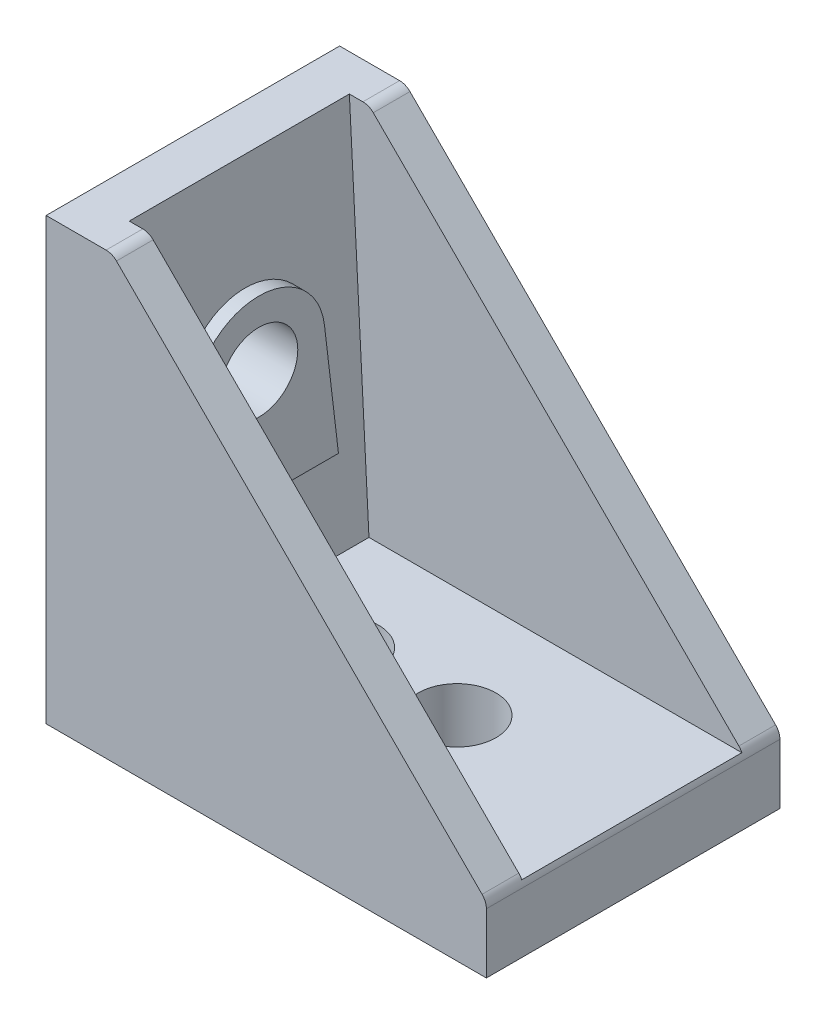
from build123d import *

# Parameters (mm, degrees)
BOSS_EXTRUDE1_DEPTH = 10
CUT_EXTRUDE1_DEPTH  = 7.5
BOSS_EXTRUDE2_DEPTH = 4.5
DIAMETER_HOLE1_D    = 5.3
BOSS_EXTRUDE3_START = 1
BOSS_EXTRUDE3_DEPTH = 1
DIAMETER_HOLE2_D    = 5.3
BOSS_EXTRUDE4_DEPTH = 1


with BuildPart() as part:
    # Sketch1 → Boss-Extrude1 (new, symmetric)
    with BuildSketch(Plane.XY):
        with BuildLine():
            Line((0, 0), (0, 30))
            Line((0, 30), (4.085786438, 30))
            ThreePointArc((4.085786438, 30), (4.46846987, 29.923879533), (4.792893219, 29.707106781))
            Line((4.792893219, 29.707106781), (29.707106781, 4.792893219))
            ThreePointArc((29.707106781, 4.792893219), (29.923879533, 4.46846987), (30, 4.085786438))
            Line((30, 4.085786438), (30, 0))
            Line((30, 0), (0, 0))
        make_face()
    extrude(amount=BOSS_EXTRUDE1_DEPTH, both=True)

    # Sketch2 → Cut-Extrude1 (cut, symmetric)
    with BuildSketch(Plane.XY):
        with BuildLine():
            Line((3.163601628, 30), (4.5, 4.5))
            Line((4.5, 4.5), (29.910179721, 4.5))
            ThreePointArc((29.910179721, 4.5), (29.821797126, 4.655566643), (29.707106781, 4.792893219))
            Line((29.707106781, 4.792893219), (4.792893219, 29.707106781))
            ThreePointArc((4.792893219, 29.707106781), (4.46846987, 29.923879533), (4.085786438, 30))
            Line((4.085786438, 30), (3.163601628, 30))
        make_face()
    extrude(amount=CUT_EXTRUDE1_DEPTH, both=True, mode=Mode.SUBTRACT)

    # Sketch3 → Boss-Extrude2 (add)
    with BuildSketch(Plane.ZY):
        with BuildLine():
            Line((-5.420869488, 10.5), (5.420869488, 10.5))
            Line((5.420869488, 10.5), (4.468692558, 18.529893219))
            ThreePointArc((4.468692558, 18.529893219), (0, 22.5), (-4.468692558, 18.529893219))
            Line((-4.468692558, 18.529893219), (-5.420869488, 10.5))
        make_face()
    extrude(amount=-BOSS_EXTRUDE2_DEPTH)

    # Diameter Hole1 (through all)
    with Locations(Plane(origin=(0, 4.5, 0), x_dir=(1, 0, 0), z_dir=(0, 1, 0))):
        with Locations((10, 0), (18, 0)):
            Hole(DIAMETER_HOLE1_D / 2)

    # Sketch6 → Boss-Extrude3 (add)
    with BuildSketch(Plane.XZ.offset(BOSS_EXTRUDE3_START)):
        with BuildLine():
            Line((13, -0.5), (12.602402736, -0.5))
            ThreePointArc((12.602402736, -0.5), (11.87383297, -1.87383297), (10.5, -2.602402736))
            Line((10.5, -2.602402736), (10.5, -3))
            Line((10.5, -3), (12, -3))
            ThreePointArc((12, -3), (12.707106781, -2.707106781), (13, -2))
            Line((13, -2), (13, -0.5))
        make_face()
        with BuildLine():
            Line((9.5, -3), (9.5, -2.602402736))
            ThreePointArc((9.5, -2.602402736), (8.12616703, -1.87383297), (7.397597264, -0.5))
            Line((7.397597264, -0.5), (7, -0.5))
            Line((7, -0.5), (7, -2))
            ThreePointArc((7, -2), (7.292893219, -2.707106781), (8, -3))
            Line((8, -3), (9.5, -3))
        make_face()
        with BuildLine():
            Line((9.5, 2.602402736), (9.5, 3))
            Line((9.5, 3), (8, 3))
            ThreePointArc((8, 3), (7.292893219, 2.707106781), (7, 2))
            Line((7, 2), (7, 0.5))
            Line((7, 0.5), (7.397597264, 0.5))
            ThreePointArc((7.397597264, 0.5), (8.12616703, 1.87383297), (9.5, 2.602402736))
        make_face()
        with BuildLine():
            Line((12, 3), (10.5, 3))
            Line((10.5, 3), (10.5, 2.602402736))
            ThreePointArc((10.5, 2.602402736), (11.87383297, 1.87383297), (12.602402736, 0.5))
            Line((12.602402736, 0.5), (13, 0.5))
            Line((13, 0.5), (13, 2))
            ThreePointArc((13, 2), (12.707106781, 2.707106781), (12, 3))
        make_face()
    extrude(amount=-BOSS_EXTRUDE3_DEPTH)

    # Diameter Hole2 (through all)
    with Locations(Plane(origin=(4.5, 0, 0), x_dir=(0, 0, -1), z_dir=(1, 0, 0))):
        with Locations((0, 18)):
            Hole(DIAMETER_HOLE2_D / 2)

    # Sketch9 → Boss-Extrude4 (add)
    with BuildSketch(Plane.ZY):
        with BuildLine():
            Line((-2.7, 24), (2.7, 24))
            ThreePointArc((2.7, 24), (2.912132034, 24.087867966), (3, 24.3))
            Line((3, 24.3), (3, 26.7))
            ThreePointArc((3, 26.7), (2.912132034, 26.912132034), (2.7, 27))
            Line((2.7, 27), (-2.7, 27))
            ThreePointArc((-2.7, 27), (-2.912132034, 26.912132034), (-3, 26.7))
            Line((-3, 26.7), (-3, 24.3))
            ThreePointArc((-3, 24.3), (-2.912132034, 24.087867966), (-2.7, 24))
        make_face()
        with BuildLine():
            Line((-2.7, 5), (2.7, 5))
            ThreePointArc((2.7, 5), (2.912132034, 5.087867966), (3, 5.3))
            Line((3, 5.3), (3, 10.7))
            ThreePointArc((3, 10.7), (2.912132034, 10.912132034), (2.7, 11))
            Line((2.7, 11), (-2.7, 11))
            ThreePointArc((-2.7, 11), (-2.912132034, 10.912132034), (-3, 10.7))
            Line((-3, 10.7), (-3, 5.3))
            ThreePointArc((-3, 5.3), (-2.912132034, 5.087867966), (-2.7, 5))
        make_face()
    extrude(amount=BOSS_EXTRUDE4_DEPTH)


solid = part.part
